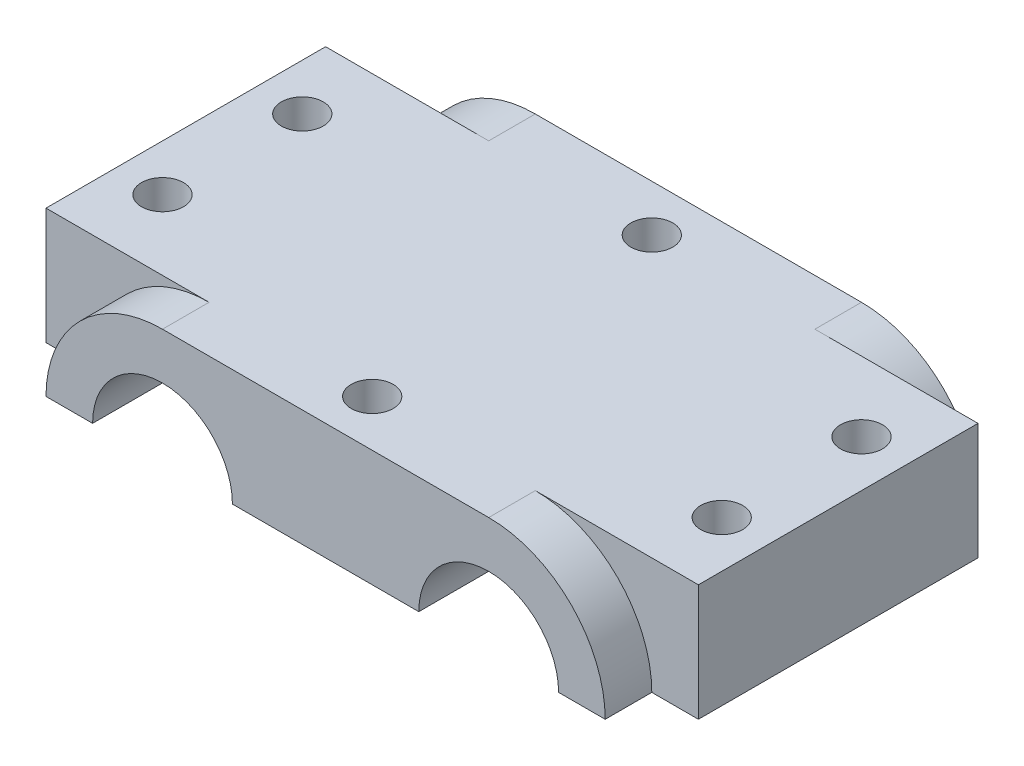
from build123d import *

# Parameters (mm, degrees)
BOSS_EXTRUDE1_DEPTH = 5
SKETCH2_W           = 70
SKETCH2_H           = 12.5
BOSS_EXTRUDE2_DEPTH = 15
SKETCH3_R           = 2.25
CUT_EXTRUDE1_DEPTH  = 15
CUT_EXTRUDE2_DEPTH  = 15
CUT_EXTRUDE3_DEPTH  = 15


with BuildPart() as part:
    # Sketch1 → Boss-Extrude1 (new body)
    with BuildSketch(Plane.XY):
        with BuildLine():
            Line((-17.5, 12.5), (17.5, 12.5))
            ThreePointArc((17.5, 12.5), (26.338834765, 8.838834765), (30, 0))
            Line((30, 0), (25, 0))
            ThreePointArc((25, 0), (17.5, 7.5), (10, 0))
            Line((10, 0), (-10, 0))
            ThreePointArc((-10, 0), (-17.5, 7.5), (-25, 0))
            Line((-25, 0), (-30, 0))
            ThreePointArc((-30, 0), (-26.338834765, 8.838834765), (-17.5, 12.5))
        make_face()
    extrude(amount=BOSS_EXTRUDE1_DEPTH)

    # Sketch2 → Boss-Extrude2 (add)
    with BuildSketch(Plane(origin=(0, 0, 0), x_dir=(-1, 0, 0), z_dir=(0, 0, -1))):
        with Locations((0, 6.25)):
            Rectangle(SKETCH2_W, SKETCH2_H)
    extrude(amount=BOSS_EXTRUDE2_DEPTH)

    # Sketch3 → Cut-Extrude1 (cut)
    with BuildSketch(Plane(origin=(0, 12.5, 0), x_dir=(1, 0, 0), z_dir=(0, 1, 0))):
        Circle(SKETCH3_R)
        with Locations((30, 7.5)):
            Circle(SKETCH3_R)
        with Locations((-30, 7.5)):
            Circle(SKETCH3_R)
    extrude(amount=-CUT_EXTRUDE1_DEPTH, mode=Mode.SUBTRACT)

    # Sketch5 → Cut-Extrude2 (cut)
    with BuildSketch(Plane.XY):
        with BuildLine():
            Line((-25, 0), (-10, 0))
            ThreePointArc((-10, 0), (-17.5, 7.5), (-25, 0))
        make_face()
    extrude(amount=-CUT_EXTRUDE2_DEPTH, mode=Mode.SUBTRACT)

    # Sketch6 → Cut-Extrude3 (cut)
    with BuildSketch(Plane.XY):
        with BuildLine():
            Line((10, 0), (25, 0))
            ThreePointArc((25, 0), (17.5, 7.5), (10, 0))
        make_face()
    extrude(amount=-CUT_EXTRUDE3_DEPTH, mode=Mode.SUBTRACT)

    # Mirror1: part across plane


with BuildPart() as part_1:
    add(part.part)
    add(part.part.mirror(Plane(origin=(0, 0, -15), x_dir=(1, 0, 0), z_dir=(0, 0, -1))))


solid = part_1.part
